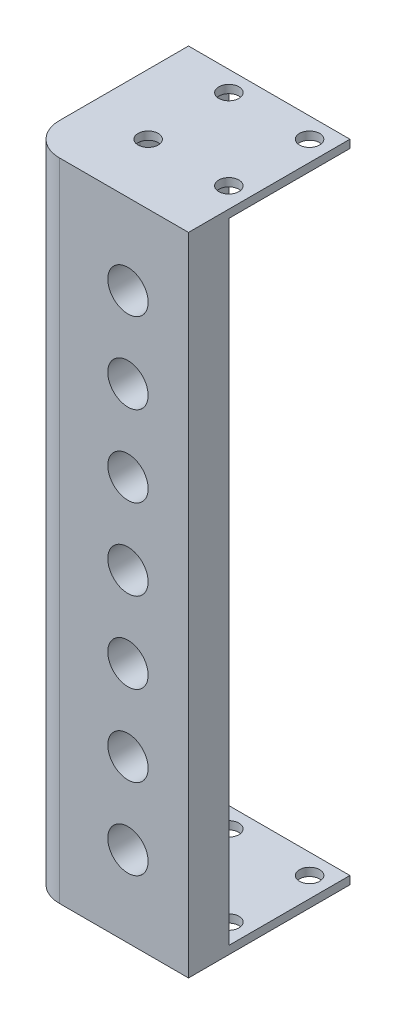
from build123d import *

# Parameters (mm, degrees)
BOSS_EXTRUDE1_DEPTH = 203.2
FILLET1_R           = 10.16
SKETCH3_R           = 6.35
CUT_EXTRUDE1_DEPTH  = 51.8
SKETCH4_R           = 6.35
CUT_EXTRUDE2_DEPTH  = 51.8
SKETCH5_R           = 3.175
BOSS_EXTRUDE2_DEPTH = 2.54


with BuildPart() as part:
    # Sketch2 → Boss-Extrude1 (new body)
    with BuildSketch(Plane(origin=(0, 0, 0), x_dir=(1, 0, 0), z_dir=(0, 1, 0))):
        Polygon((0, 0), (50.8, 0), (50.8, 12.7), (12.7, 12.7), (12.7, 50.8), (0, 50.8), align=None)
    extrude(amount=BOSS_EXTRUDE1_DEPTH)

    # Fillet1
    fillet1_edges = [part.edges().sort_by_distance(p)[0] for p in [
        (12.7, 101.6, -12.7),
        (0, 101.6, 0),
    ]]
    fillet(fillet1_edges, radius=FILLET1_R)

    # Sketch3 → Cut-Extrude1 (cut, through all)
    with BuildSketch(Plane.XY):
        with Locations((31.75, 177.8)):
            Circle(SKETCH3_R)
        with Locations((31.75, 152.4)):
            Circle(SKETCH3_R)
        with Locations((31.75, 127)):
            Circle(SKETCH3_R)
        with Locations((31.75, 101.6)):
            Circle(SKETCH3_R)
        with Locations((31.75, 76.2)):
            Circle(SKETCH3_R)
        with Locations((31.75, 50.8)):
            Circle(SKETCH3_R)
        with Locations((31.75, 25.4)):
            Circle(SKETCH3_R)
    extrude(amount=-CUT_EXTRUDE1_DEPTH, mode=Mode.SUBTRACT)

    # Sketch4 → Cut-Extrude2 (cut, through all)
    with BuildSketch(Plane.ZY):
        with Locations((-31.75, 177.8)):
            Circle(SKETCH4_R)
        with Locations((-31.75, 152.4)):
            Circle(SKETCH4_R)
        with Locations((-31.75, 127)):
            Circle(SKETCH4_R)
        with Locations((-31.75, 101.6)):
            Circle(SKETCH4_R)
        with Locations((-31.75, 76.2)):
            Circle(SKETCH4_R)
        with Locations((-31.75, 50.8)):
            Circle(SKETCH4_R)
        with Locations((-31.75, 25.4)):
            Circle(SKETCH4_R)
    extrude(amount=-CUT_EXTRUDE2_DEPTH, mode=Mode.SUBTRACT)

    # Sketch5 → Boss-Extrude2 (add)
    with BuildSketch(Plane(origin=(0, 203.2, 0), x_dir=(1, 0, 0), z_dir=(0, 1, 0))):
        with BuildLine():
            Line((50.8, 50.8), (12.7, 50.8))
            Line((12.7, 50.8), (12.7, 22.86))
            ThreePointArc((12.7, 22.86), (15.675795103, 15.675795103), (22.86, 12.7))
            Line((22.86, 12.7), (50.8, 12.7))
            Line((50.8, 12.7), (50.8, 50.8))
        make_face()
        with Locations((19.05, 19.05)):
            Circle(SKETCH5_R, mode=Mode.SUBTRACT)
        with Locations((44.45, 19.05)):
            Circle(SKETCH5_R, mode=Mode.SUBTRACT)
        with Locations((19.05, 44.45)):
            Circle(SKETCH5_R, mode=Mode.SUBTRACT)
        with Locations((44.45, 44.45)):
            Circle(SKETCH5_R, mode=Mode.SUBTRACT)
    boss_extrude2 = extrude(amount=-BOSS_EXTRUDE2_DEPTH)

    # Mirror1: Boss-Extrude2 across plane
    add(boss_extrude2.mirror(Plane.ZX.offset(101.6)))


solid = part.part
